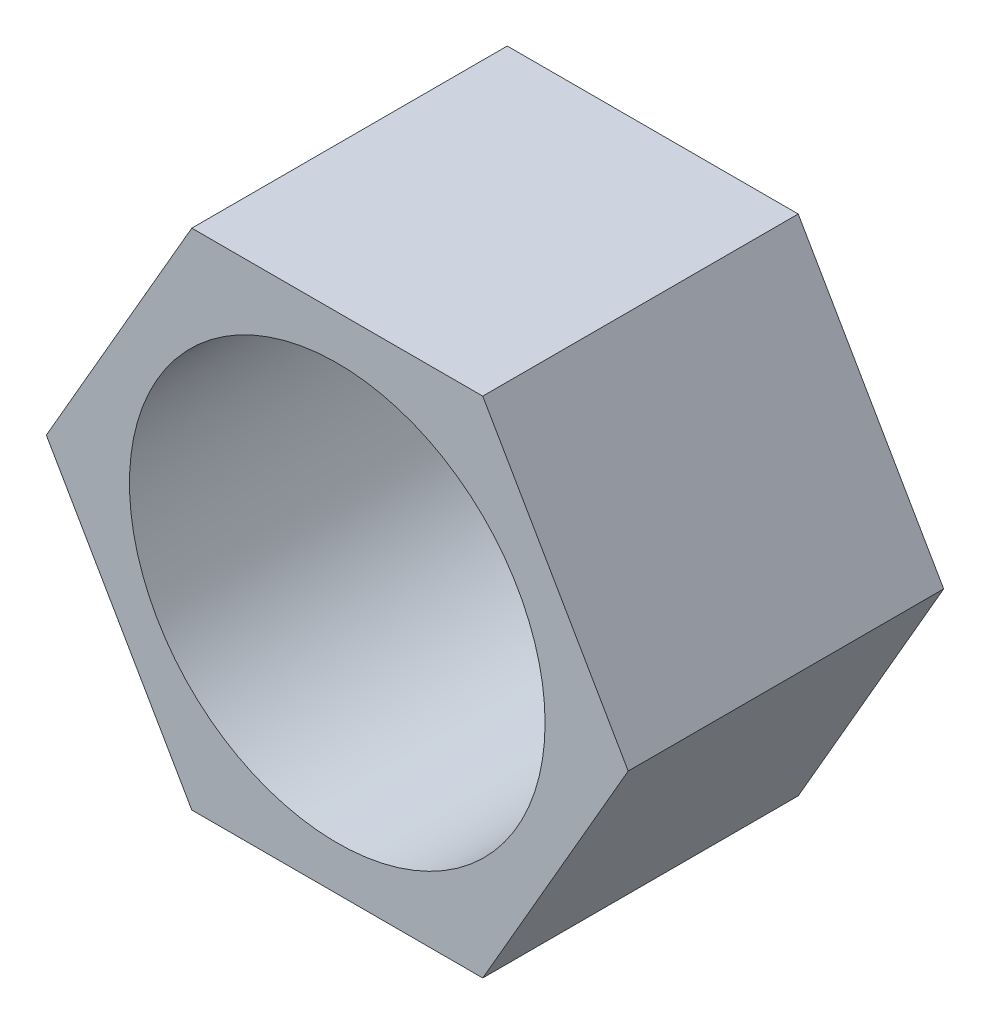
from build123d import *

# Parameters (mm, degrees)
SKETCH2_R           = 5
BOSS_EXTRUDE1_DEPTH = 7.59


with BuildPart() as part:
    # Sketch2 → Boss-Extrude1 (new body)
    with BuildSketch(Plane.XY):
        Polygon((7, 0), (3.5, 6.062177826), (-3.5, 6.062177826), (-7, 0), (-3.5, -6.062177826), (3.5, -6.062177826), align=None)
        Circle(SKETCH2_R, mode=Mode.SUBTRACT)
    extrude(amount=BOSS_EXTRUDE1_DEPTH)


solid = part.part
